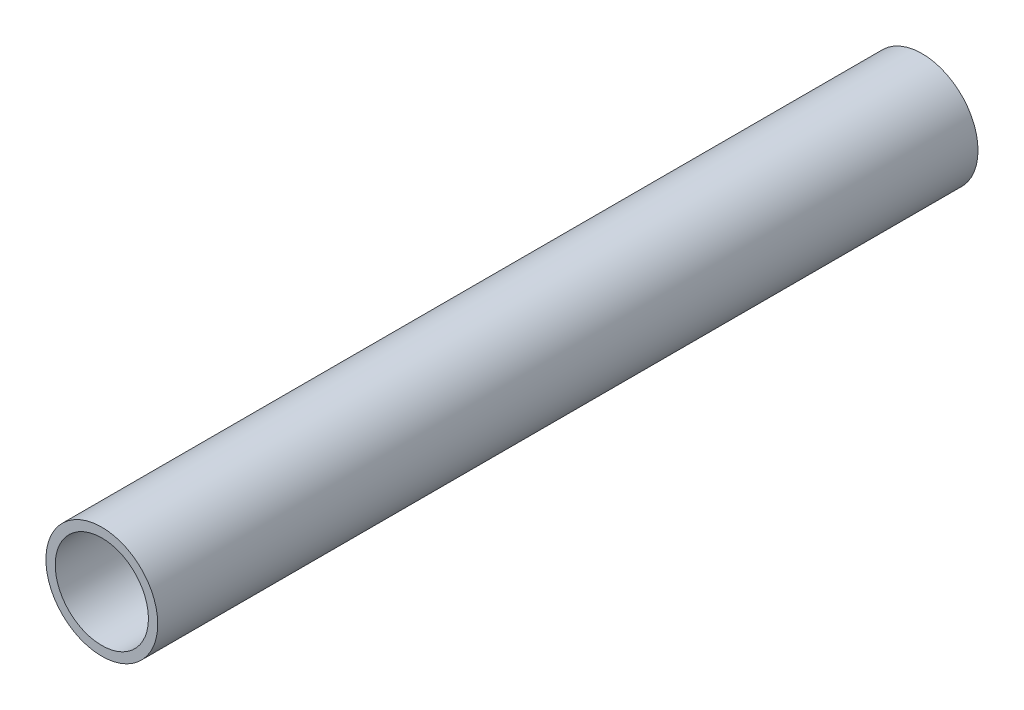
from build123d import *

# Parameters (mm, degrees)
SKETCH2_R      = 19.05
SKETCH2_R_2    = 15.875
EXTRUDE1_DEPTH = 279.4


with BuildPart() as part:
    # Sketch2 → Extrude1 (new body)
    with BuildSketch(Plane.XY):
        Circle(SKETCH2_R)
        Circle(SKETCH2_R_2, mode=Mode.SUBTRACT)
    extrude(amount=EXTRUDE1_DEPTH)


solid = part.part
